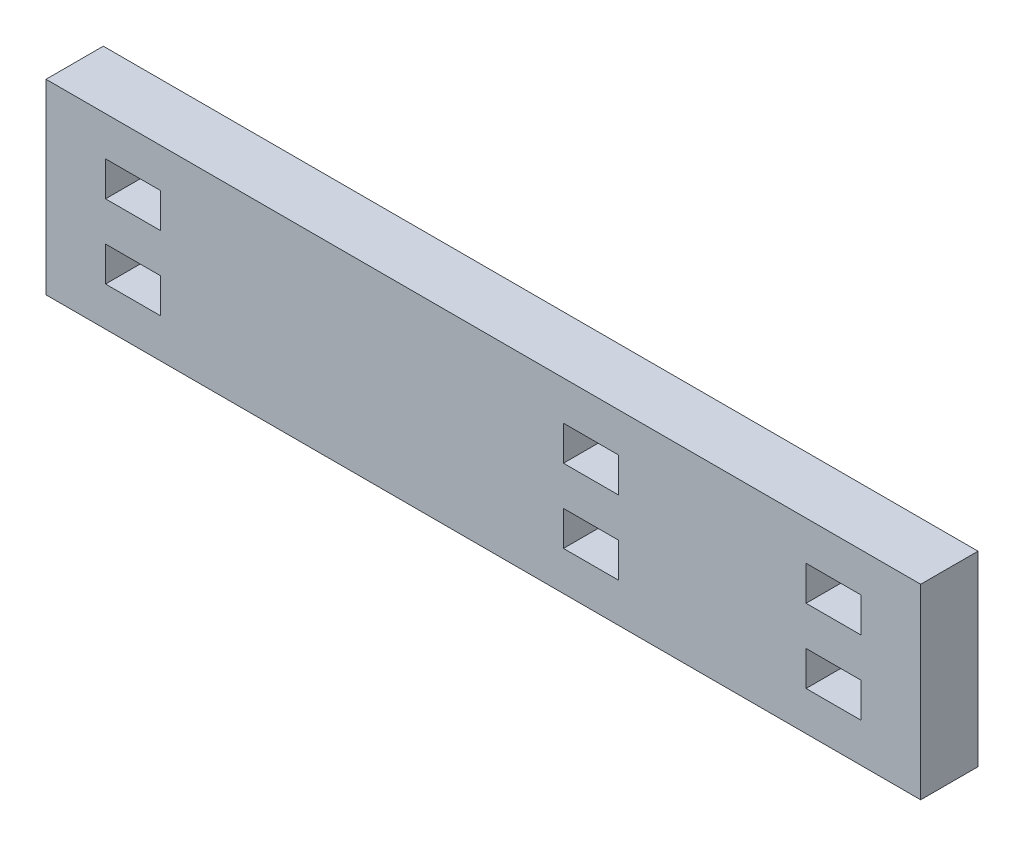
from build123d import *

# Parameters (mm, degrees)
SKETCH1_W           = 78.6
SKETCH1_H           = 16.777
BOSS_EXTRUDE1_DEPTH = 5.15
SKETCH2_W           = 4.95
SKETCH2_H           = 3.1154
CUT_EXTRUDE1_DEPTH  = 6.15


with BuildPart() as part:
    # Sketch1 → Boss-Extrude1 (new body)
    with BuildSketch(Plane.XY):
        with Locations((39.2, 8.2885)):
            Rectangle(SKETCH1_W, SKETCH1_H)
    extrude(amount=BOSS_EXTRUDE1_DEPTH)

    # Sketch2 → Cut-Extrude1 (cut, through all)
    with BuildSketch(Plane.XY.offset(5.15)):
        with Locations((7.725, 11.6039)):
            Rectangle(SKETCH2_W, SKETCH2_H)
        with Locations((7.725, 4.9731)):
            Rectangle(SKETCH2_W, SKETCH2_H)
        with Locations((48.875, 11.6039)):
            Rectangle(SKETCH2_W, SKETCH2_H)
        with Locations((48.875, 4.9731)):
            Rectangle(SKETCH2_W, SKETCH2_H)
        with Locations((70.675, 11.6039)):
            Rectangle(SKETCH2_W, SKETCH2_H)
        with Locations((70.675, 4.9731)):
            Rectangle(SKETCH2_W, SKETCH2_H)
    extrude(amount=-CUT_EXTRUDE1_DEPTH, mode=Mode.SUBTRACT)


solid = part.part
